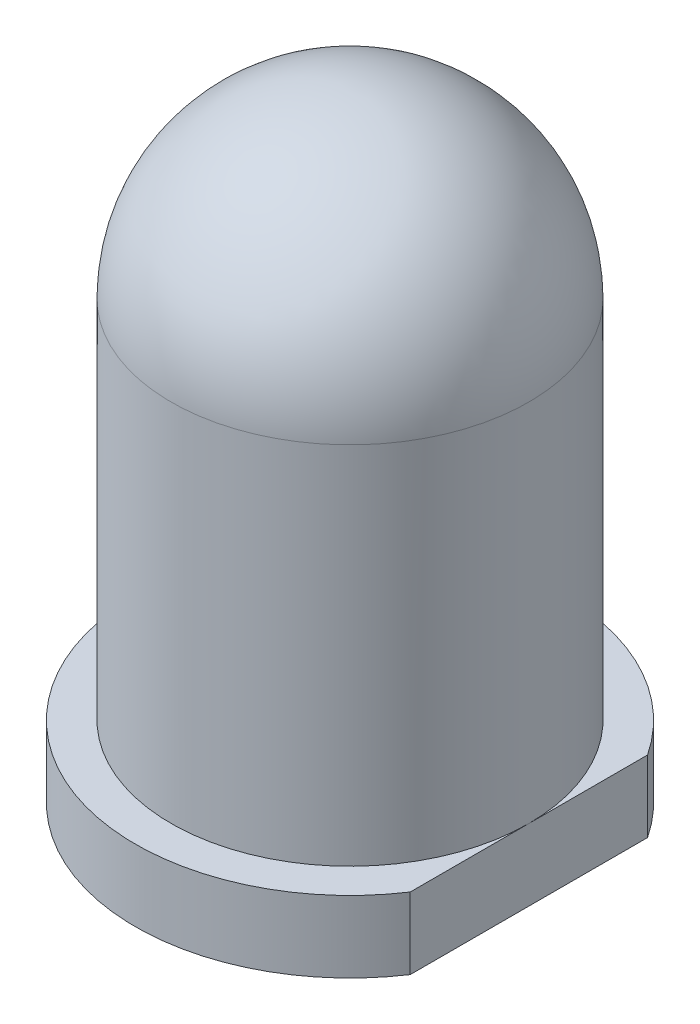
from build123d import *

# Parameters (mm, degrees)
SKICA2_W                 = 0.905409292
SKICA2_H                 = 5.783897519
ODEBRAT_VYSUNUT_M2_DEPTH = 10


with BuildPart() as part:
    # Skica1 → Rotovat1 (revolve)
    with BuildSketch(Plane.XY):
        with BuildLine():
            Line((0, 0), (-3, 0))
            Line((-3, 0), (-3, 1))
            Line((-3, 1), (-2.5, 1))
            Line((-2.5, 1), (-2.5, 6.1))
            ThreePointArc((-2.5, 6.1), (-1.767766953, 7.867766953), (0, 8.6))
            Line((0, 8.6), (0, 0))
        make_face()
    revolve(axis=Axis((0, 0, 0), (0, 1, 0)))

    # Skica2 → Odebrat vysunutím2 (cut)
    with BuildSketch(Plane(origin=(0, 0, 0), x_dir=(1, 0, 0), z_dir=(0, 1, 0))):
        with Locations((2.952704646, -0.166785923)):
            Rectangle(SKICA2_W, SKICA2_H)
    extrude(amount=ODEBRAT_VYSUNUT_M2_DEPTH, mode=Mode.SUBTRACT)


solid = part.part
